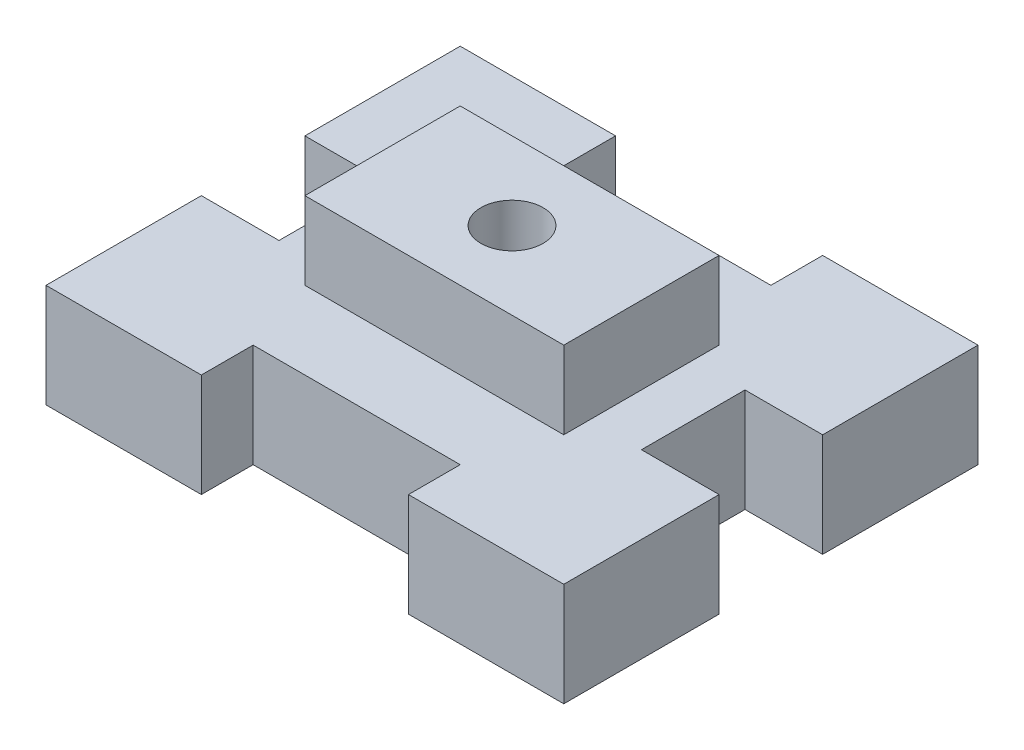
from build123d import *

# Parameters (mm, degrees)
BOSS_EXTRUDE1_DEPTH      = 10
BOSS_EXTRUDE1_DEPTH_BACK = 10
BOSS_EXTRUDE2_DEPTH      = 25
BOSS_EXTRUDE2_DEPTH_BACK = 25
SKETCH2_W                = 50
SKETCH2_H                = 30
SKETCH3_R                = 6
CUT_EXTRUDE1_DEPTH       = 138.477270849


with BuildPart() as part:
    # Sketch1 → Boss-Extrude1 (new, two sides: drawn at the far end of the back side and taken through both)
    with BuildSketch(Plane(origin=(0, 0, 0), x_dir=(1, 0, 0), z_dir=(0, 1, 0)).offset(-BOSS_EXTRUDE1_DEPTH_BACK)):
        Polygon((0, 0), (30, 0), (30, -10), (70, -10), (70, 0), (100, 0), (100, -30), (85, -30), (85, -50), (100, -50), (100, -80), (70, -80), (70, -70), (30, -70), (30, -80), (0, -80), (0, -50), (15, -50), (15, -30), (0, -30), align=None)
    extrude(amount=BOSS_EXTRUDE1_DEPTH + BOSS_EXTRUDE1_DEPTH_BACK)

    # Sketch2 → Boss-Extrude2 (add, two sides: drawn at the far end of the back side and taken through both)
    with BuildSketch(Plane(origin=(0, 0, 0), x_dir=(1, 0, 0), z_dir=(0, 1, 0)).offset(-BOSS_EXTRUDE2_DEPTH_BACK)):
        with Locations((50, -40)):
            Rectangle(SKETCH2_W, SKETCH2_H)
    extrude(amount=BOSS_EXTRUDE2_DEPTH + BOSS_EXTRUDE2_DEPTH_BACK)

    # Sketch3 → Cut-Extrude1 (cut, through all)
    with BuildSketch(Plane(origin=(0, 25, 0), x_dir=(1, 0, 0), z_dir=(0, 1, 0))):
        with Locations((50, -40)):
            Circle(SKETCH3_R)
    extrude(amount=-CUT_EXTRUDE1_DEPTH, mode=Mode.SUBTRACT)


solid = part.part
